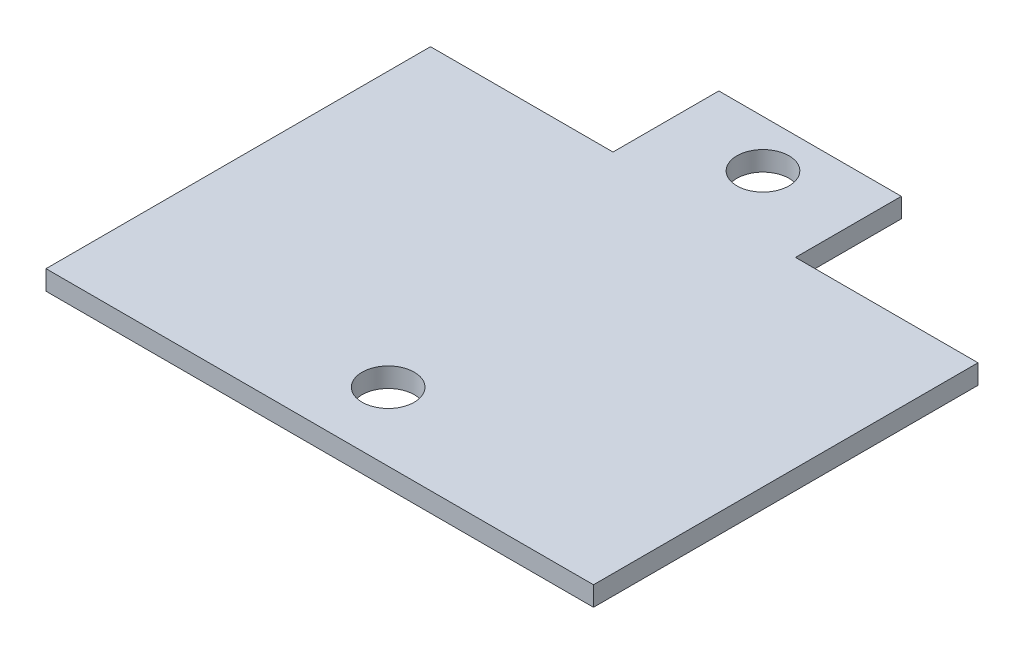
from build123d import *

# Parameters (mm, degrees)
SKETCH_1_R      = 2
EXTRUDE_1_DEPTH = 1.5


with BuildPart() as part:
    # Эскиз1 → Бобышка-Вытянуть1 (new body)
    with BuildSketch(Plane(origin=(0, 0, 0), x_dir=(1, 0, 0), z_dir=(0, 1, 0))):
        Polygon((0, 29.496468405), (14, 29.496468405), (14, 37.614912407), (28, 37.614912407), (28, 29.496468405), (42, 29.496468405), (42, 0), (0, 0), align=None)
        with Locations((21, 5.25)):
            Circle(SKETCH_1_R, mode=Mode.SUBTRACT)
        with Locations((21, 34)):
            Circle(SKETCH_1_R, mode=Mode.SUBTRACT)
    extrude(amount=EXTRUDE_1_DEPTH)


solid = part.part
